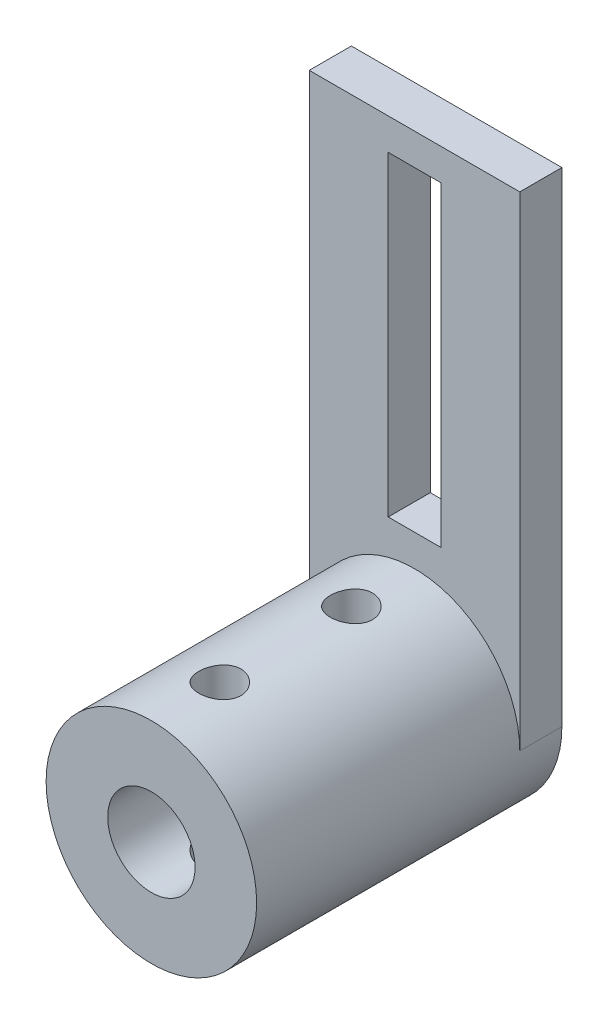
from build123d import *

# Parameters (mm, degrees)
CROQUIS1_W              = 5
CROQUIS1_H              = 30
SALIENTE_EXTRUIR1_DEPTH = 4
SALIENTE_EXTRUIR2_START = 4
CROQUIS2_R              = 10
CROQUIS2_R_2            = 4.15
SALIENTE_EXTRUIR2_DEPTH = 25
CORTAR_EXTRUIR1_START   = 4
CROQUIS3_R              = 4.15
CORTAR_EXTRUIR1_DEPTH   = 4
CROQUIS4_R              = 2
CORTAR_EXTRUIR2_DEPTH   = 29


with BuildPart() as part:
    # Croquis1 → Saliente-Extruir1 (new body)
    with BuildSketch(Plane.XY):
        with BuildLine():
            Line((10, -18), (10, 28))
            Line((10, 28), (-10, 28))
            Line((-10, 28), (-10, -18))
            ThreePointArc((-10, -18), (0, -28), (10, -18))
        make_face()
        with Locations((0, 10)):
            Rectangle(CROQUIS1_W, CROQUIS1_H, mode=Mode.SUBTRACT)
    extrude(amount=SALIENTE_EXTRUIR1_DEPTH)

    # Croquis2 → Saliente-Extruir2 (add)
    with BuildSketch(Plane.XY.offset(SALIENTE_EXTRUIR2_START)):
        with Locations((0, -18)):
            Circle(CROQUIS2_R)
        with Locations((0, -18)):
            Circle(CROQUIS2_R_2, mode=Mode.SUBTRACT)
    extrude(amount=SALIENTE_EXTRUIR2_DEPTH)

    # Croquis3 → Cortar-Extruir1 (cut)
    with BuildSketch(Plane.XY.offset(CORTAR_EXTRUIR1_START)):
        with Locations((0, -18)):
            Circle(CROQUIS3_R)
    extrude(amount=-CORTAR_EXTRUIR1_DEPTH, mode=Mode.SUBTRACT)

    # Croquis4 → Cortar-Extruir2 (cut, through all)
    with BuildSketch(Plane(origin=(0, 0, 0), x_dir=(1, 0, 0), z_dir=(0, 1, 0))):
        with Locations((0, -10)):
            Circle(CROQUIS4_R)
        with Locations((0, -22.5)):
            Circle(CROQUIS4_R)
    extrude(amount=-CORTAR_EXTRUIR2_DEPTH, mode=Mode.SUBTRACT)


solid = part.part
